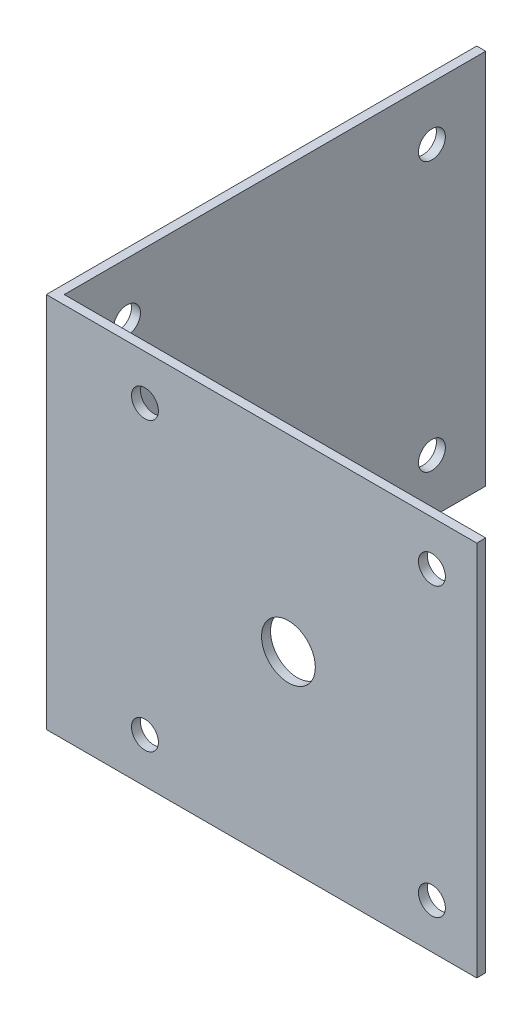
from build123d import *

# Parameters (mm, degrees)
BOSS_EXTRUDE1_DEPTH = 42
SKETCH2_R           = 1.5
SKETCH2_R_2         = 3
CUT_EXTRUDE1_DEPTH  = 42
SKETCH3_R           = 1.5
CUT_EXTRUDE2_DEPTH  = 42


with BuildPart() as part:
    # Sketch1 → Boss-Extrude1 (new body)
    with BuildSketch(Plane(origin=(0, 0, 0), x_dir=(1, 0, 0), z_dir=(0, 1, 0))):
        Polygon((0, 0), (0, 48), (1, 48), (1, 1), (48, 1), (48, 0), align=None)
    extrude(amount=BOSS_EXTRUDE1_DEPTH)

    # Sketch2 → Cut-Extrude1 (cut)
    with BuildSketch(Plane.XY):
        with Locations((11, 37)):
            Circle(SKETCH2_R)
        with Locations((43, 37)):
            Circle(SKETCH2_R)
        with Locations((43, 5)):
            Circle(SKETCH2_R)
        with Locations((11, 5)):
            Circle(SKETCH2_R)
        with Locations((27, 21)):
            Circle(SKETCH2_R_2)
    extrude(amount=-CUT_EXTRUDE1_DEPTH, mode=Mode.SUBTRACT)

    # Sketch3 → Cut-Extrude2 (cut)
    with BuildSketch(Plane(origin=(0, 0, 0), x_dir=(0, 0, -1), z_dir=(1, 0, 0))):
        with Locations((42, 36)):
            Circle(SKETCH3_R)
        with Locations((42, 6)):
            Circle(SKETCH3_R)
        with Locations((8, 6)):
            Circle(SKETCH3_R)
        with Locations((8, 36)):
            Circle(SKETCH3_R)
    extrude(amount=CUT_EXTRUDE2_DEPTH, mode=Mode.SUBTRACT)


solid = part.part
